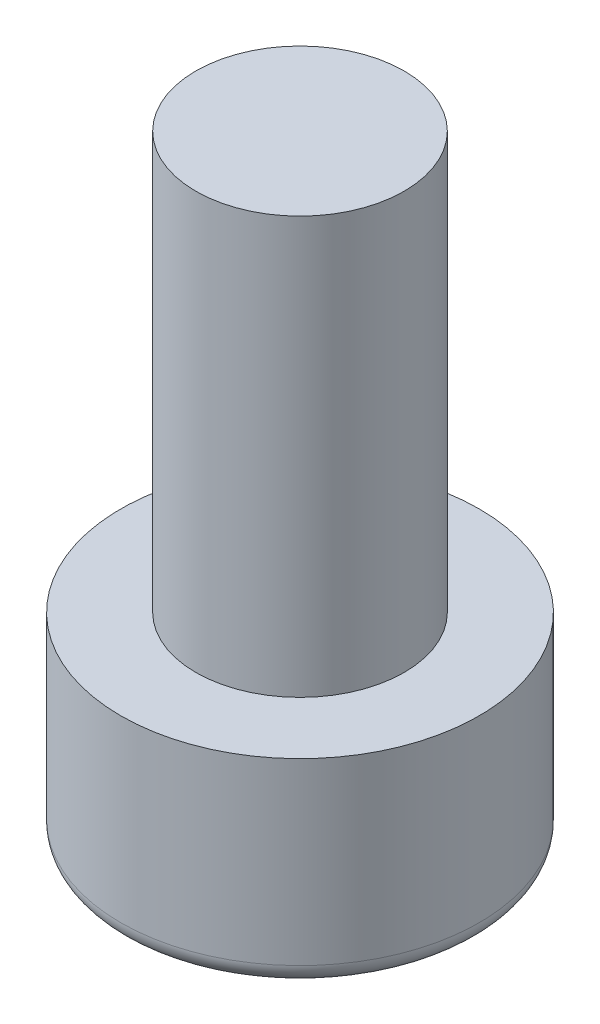
from build123d import *

# Parameters (mm, degrees)
SKETCH2_R           = 4.3
BOSS_EXTRUDE1_DEPTH = 4.8
SKETCH3_R           = 2.5
BOSS_EXTRUDE2_DEPTH = 10
CUT_EXTRUDE1_DEPTH  = 3.25
FILLET1_R           = 0.5


with BuildPart() as part:
    # Sketch2 → Boss-Extrude1 (new body)
    with BuildSketch(Plane(origin=(0, 0, 0), x_dir=(1, 0, 0), z_dir=(0, 1, 0))):
        Circle(SKETCH2_R)
    extrude(amount=BOSS_EXTRUDE1_DEPTH)

    # Sketch3 → Boss-Extrude2 (add)
    with BuildSketch(Plane(origin=(0, 4.8, 0), x_dir=(1, 0, 0), z_dir=(0, 1, 0))):
        Circle(SKETCH3_R)
    extrude(amount=BOSS_EXTRUDE2_DEPTH)

    # Sketch5 → Cut-Extrude1 (cut)
    with BuildSketch(Plane.XZ):
        Polygon((-1.154700538, 2), (-2.309401077, 0), (-1.154700538, -2), (1.154700538, -2), (2.309401077, 0), (1.154700538, 2), align=None)
    extrude(amount=-CUT_EXTRUDE1_DEPTH, mode=Mode.SUBTRACT)

    # Fillet1
    fillet1_edges = [part.edges().sort_by_distance(p)[0] for p in [
        (0, 3.25, 2),
        (1.732050808, 3.25, 1),
        (1.732050808, 3.25, -1),
        (0, 3.25, -2),
        (-1.732050808, 3.25, -1),
        (-1.732050808, 3.25, 1),
        (0, 0, 2),
        (-1.732050808, 0, 1),
        (-1.732050808, 0, -1),
        (0, 0, -2),
        (1.732050808, 0, -1),
        (1.732050808, 0, 1),
        (-4.3, 0, 0),
    ]]
    fillet(fillet1_edges, radius=FILLET1_R)


solid = part.part
